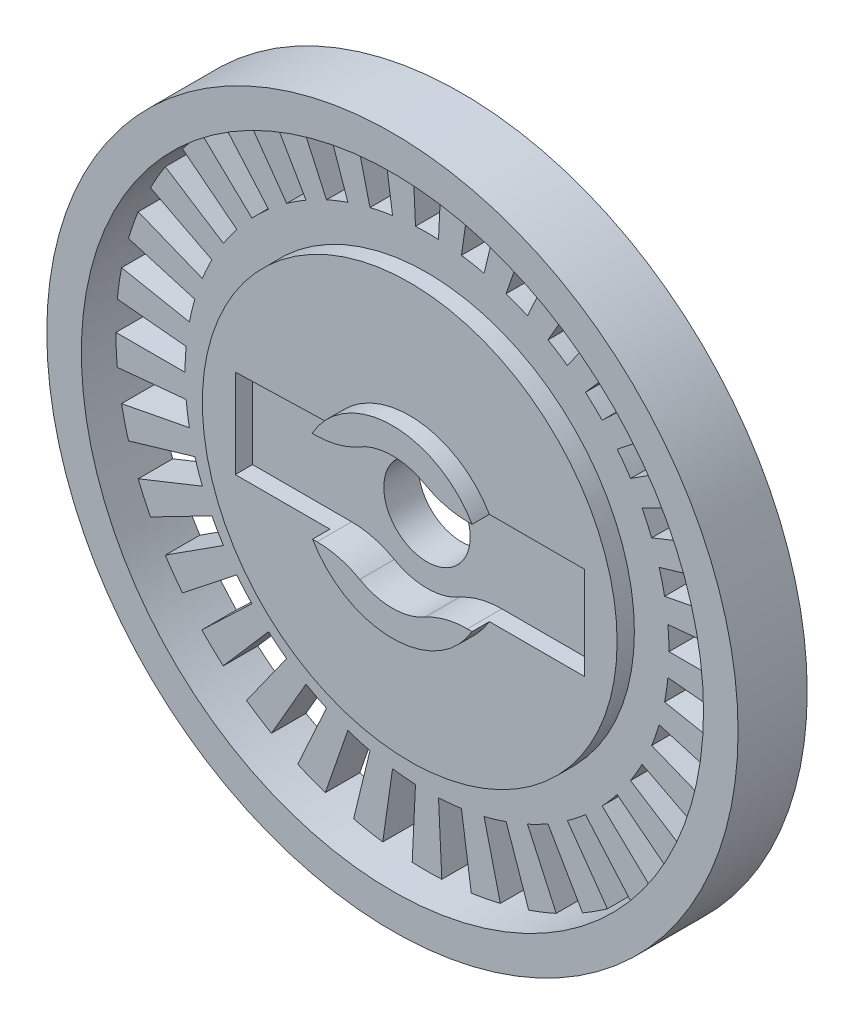
from build123d import *

# Parameters (mm, degrees)
SKETCH1_R           = 20
BOSS_EXTRUDE1_DEPTH = 4
SKETCH2_R           = 2.5
CUT_EXTRUDE1_DEPTH  = 4
CUT_EXTRUDE2_DEPTH  = 2
CUT_EXTRUDE3_DEPTH  = 4
SKETCH5_R           = 18
SKETCH5_R_2         = 12
CUT_EXTRUDE4_DEPTH  = 2
SKETCH6_R           = 13.335707923
SKETCH6_R_2         = 5.335707923
CUT_EXTRUDE5_DEPTH  = 1
FILLET2_R           = 5


with BuildPart() as part:
    # Sketch1 → Boss-Extrude1 (new body)
    with BuildSketch(Plane.XY):
        Circle(SKETCH1_R)
    extrude(amount=BOSS_EXTRUDE1_DEPTH)

    # Sketch2 → Cut-Extrude1 (cut)
    with BuildSketch(Plane.XY.offset(4)):
        Circle(SKETCH2_R)
    extrude(amount=-CUT_EXTRUDE1_DEPTH, mode=Mode.SUBTRACT)

    # Sketch3 → Cut-Extrude2 (cut)
    with BuildSketch(Plane.XY.offset(4)):
        with BuildLine():
            Line((-2.737799224, -2.671157129), (-10.093588243, -2.671157129))
            Line((-10.093588243, -2.671157129), (-10.093588243, 2.468790745))
            Line((-10.093588243, 2.468790745), (-2.739511235, 2.66940128))
            ThreePointArc((-2.739511235, 2.66940128), (-0.013401979, 3.824976521), (2.720738068, 2.688532939))
            Line((2.720738068, 2.688532939), (10.108951703, 2.688532939))
            Line((10.108951703, 2.688532939), (10.108951703, 0.003240604))
            Line((10.108951703, 0.003240604), (10.108951703, -2.686788025))
            Line((10.108951703, -2.686788025), (2.722461223, -2.686788025))
            ThreePointArc((2.722461223, -2.686788025), (-0.010949648, -3.824984327), (-2.737799224, -2.671157129))
        make_face()
    extrude(amount=-CUT_EXTRUDE2_DEPTH, mode=Mode.SUBTRACT)

    # Sketch4 → Cut-Extrude3 (cut)
    with BuildSketch(Plane.XY.offset(4)):
        with BuildLine():
            Line((13.936606916, 1.330784606), (17.918494606, 1.711008779))
            ThreePointArc((17.918494606, 1.711008779), (17.979612105, 0.856474485), (18, 0))
            Line((18, 0), (14, 0))
            ThreePointArc((14, 0), (13.984142749, 0.666146822), (13.936606916, 1.330784606))
        make_face()
        with BuildLine():
            Line((13.936606916, -1.330784606), (17.918494606, -1.711008779))
            ThreePointArc((17.918494606, -1.711008779), (17.816785954, -2.561667089), (17.674716551, -3.406522398))
            Line((17.674716551, -3.406522398), (13.747001762, -2.649517421))
            ThreePointArc((13.747001762, -2.649517421), (13.857500186, -1.992407736), (13.936606916, -1.330784606))
        make_face()
        with BuildLine():
            Line((13.432901631, -3.944255796), (17.270873525, -5.071186023))
            ThreePointArc((17.270873525, -5.071186023), (17.010014737, -5.88722334), (16.710622794, -6.689924202))
            Line((16.710622794, -6.689924202), (12.997151062, -5.203274379))
            ThreePointArc((12.997151062, -5.203274379), (13.230011462, -4.578951486), (13.432901631, -3.944255796))
        make_face()
        with BuildLine():
            Line((12.443696281, -6.415171304), (15.999038076, -8.248077391))
            ThreePointArc((15.999038076, -8.248077391), (15.588457268, -9), (15.142563591, -9.731534714))
            Line((15.142563591, -9.731534714), (11.77754946, -7.568971444))
            ThreePointArc((11.77754946, -7.568971444), (12.124355653, -7), (12.443696281, -6.415171304))
        make_face()
        with BuildLine():
            Line((11.004743326, -8.654225807), (14.148955705, -11.126861752))
            ThreePointArc((14.148955705, -11.126861752), (13.603492338, -11.787493211), (13.027212686, -12.421422207))
            Line((13.027212686, -12.421422207), (10.132276533, -9.661106161))
            ThreePointArc((10.132276533, -9.661106161), (10.580494041, -9.168050275), (11.004743326, -8.654225807))
        make_face()
        with BuildLine():
            Line((9.168050275, -10.580494041), (11.787493211, -13.603492338))
            ThreePointArc((11.787493211, -13.603492338), (11.126861752, -14.148955705), (10.441024372, -14.662367137))
            Line((10.441024372, -14.662367137), (8.120796734, -11.404063329))
            ThreePointArc((8.120796734, -11.404063329), (8.654225807, -11.004743326), (9.168050275, -10.580494041))
        make_face()
        with BuildLine():
            Line((7, -12.124355653), (9, -15.588457268))
            ThreePointArc((9, -15.588457268), (8.248077391, -15.999038076), (7.477470234, -16.373375916))
            Line((7.477470234, -16.373375916), (5.815810182, -12.734847935))
            ThreePointArc((5.815810182, -12.734847935), (6.415171304, -12.443696281), (7, -12.124355653))
        make_face()
        with BuildLine():
            Line((4.578951486, -13.230011462), (5.88722334, -17.010014737))
            ThreePointArc((5.88722334, -17.010014737), (5.071186023, -17.270873525), (4.243660839, -17.49260823))
            Line((4.243660839, -17.49260823), (3.300625097, -13.605361957))
            ThreePointArc((3.300625097, -13.605361957), (3.944255796, -13.432901631), (4.578951486, -13.230011462))
        make_face()
        with BuildLine():
            Line((1.992407736, -13.857500186), (2.561667089, -17.816785954))
            ThreePointArc((2.561667089, -17.816785954), (1.711008779, -17.918494606), (0.856474485, -17.979612105))
            Line((0.856474485, -17.979612105), (0.666146822, -13.984142749))
            ThreePointArc((0.666146822, -13.984142749), (1.330784606, -13.936606916), (1.992407736, -13.857500186))
        make_face()
        with BuildLine():
            Line((-0.666146822, -13.984142749), (-0.856474485, -17.979612105))
            ThreePointArc((-0.856474485, -17.979612105), (-1.711008779, -17.918494606), (-2.561667089, -17.816785954))
            Line((-2.561667089, -17.816785954), (-1.992407736, -13.857500186))
            ThreePointArc((-1.992407736, -13.857500186), (-1.330784606, -13.936606916), (-0.666146822, -13.984142749))
        make_face()
        with BuildLine():
            Line((-3.300625097, -13.605361957), (-4.243660839, -17.49260823))
            ThreePointArc((-4.243660839, -17.49260823), (-5.071186023, -17.270873525), (-5.88722334, -17.010014737))
            Line((-5.88722334, -17.010014737), (-4.578951486, -13.230011462))
            ThreePointArc((-4.578951486, -13.230011462), (-3.944255796, -13.432901631), (-3.300625097, -13.605361957))
        make_face()
        with BuildLine():
            Line((-5.815810182, -12.734847935), (-7.477470234, -16.373375916))
            ThreePointArc((-7.477470234, -16.373375916), (-8.248077391, -15.999038076), (-9, -15.588457268))
            Line((-9, -15.588457268), (-7, -12.124355653))
            ThreePointArc((-7, -12.124355653), (-6.415171304, -12.443696281), (-5.815810182, -12.734847935))
        make_face()
        with BuildLine():
            Line((-8.120796734, -11.404063329), (-10.441024372, -14.662367137))
            ThreePointArc((-10.441024372, -14.662367137), (-11.126861752, -14.148955705), (-11.787493211, -13.603492338))
            Line((-11.787493211, -13.603492338), (-9.168050275, -10.580494041))
            ThreePointArc((-9.168050275, -10.580494041), (-8.654225807, -11.004743326), (-8.120796734, -11.404063329))
        make_face()
        with BuildLine():
            Line((-10.132276533, -9.661106161), (-13.027212686, -12.421422207))
            ThreePointArc((-13.027212686, -12.421422207), (-13.603492338, -11.787493211), (-14.148955705, -11.126861752))
            Line((-14.148955705, -11.126861752), (-11.004743326, -8.654225807))
            ThreePointArc((-11.004743326, -8.654225807), (-10.580494041, -9.168050275), (-10.132276533, -9.661106161))
        make_face()
        with BuildLine():
            Line((-11.77754946, -7.568971444), (-15.142563591, -9.731534714))
            ThreePointArc((-15.142563591, -9.731534714), (-15.588457268, -9), (-15.999038076, -8.248077391))
            Line((-15.999038076, -8.248077391), (-12.443696281, -6.415171304))
            ThreePointArc((-12.443696281, -6.415171304), (-12.124355653, -7), (-11.77754946, -7.568971444))
        make_face()
        with BuildLine():
            Line((-12.997151062, -5.203274379), (-16.710622794, -6.689924202))
            ThreePointArc((-16.710622794, -6.689924202), (-17.010014737, -5.88722334), (-17.270873525, -5.071186023))
            Line((-17.270873525, -5.071186023), (-13.432901631, -3.944255796))
            ThreePointArc((-13.432901631, -3.944255796), (-13.230011462, -4.578951486), (-12.997151062, -5.203274379))
        make_face()
        with BuildLine():
            Line((-13.747001762, -2.649517421), (-17.674716551, -3.406522398))
            ThreePointArc((-17.674716551, -3.406522398), (-17.816785954, -2.561667089), (-17.918494606, -1.711008779))
            Line((-17.918494606, -1.711008779), (-13.936606916, -1.330784606))
            ThreePointArc((-13.936606916, -1.330784606), (-13.857500186, -1.992407736), (-13.747001762, -2.649517421))
        make_face()
        with BuildLine():
            Line((-14, 0), (-18, 0))
            ThreePointArc((-18, 0), (-17.979612105, 0.856474485), (-17.918494606, 1.711008779))
            Line((-17.918494606, 1.711008779), (-13.936606916, 1.330784606))
            ThreePointArc((-13.936606916, 1.330784606), (-13.984142749, 0.666146822), (-14, 0))
        make_face()
        with BuildLine():
            Line((-13.747001762, 2.649517421), (-17.674716551, 3.406522398))
            ThreePointArc((-17.674716551, 3.406522398), (-17.49260823, 4.243660839), (-17.270873525, 5.071186023))
            Line((-17.270873525, 5.071186023), (-13.432901631, 3.944255796))
            ThreePointArc((-13.432901631, 3.944255796), (-13.605361957, 3.300625097), (-13.747001762, 2.649517421))
        make_face()
        with BuildLine():
            Line((-12.997151062, 5.203274379), (-16.710622794, 6.689924202))
            ThreePointArc((-16.710622794, 6.689924202), (-16.373375916, 7.477470234), (-15.999038076, 8.248077391))
            Line((-15.999038076, 8.248077391), (-12.443696281, 6.415171304))
            ThreePointArc((-12.443696281, 6.415171304), (-12.734847935, 5.815810182), (-12.997151062, 5.203274379))
        make_face()
        with BuildLine():
            Line((-11.77754946, 7.568971444), (-15.142563591, 9.731534714))
            ThreePointArc((-15.142563591, 9.731534714), (-14.662367137, 10.441024372), (-14.148955705, 11.126861752))
            Line((-14.148955705, 11.126861752), (-11.004743326, 8.654225807))
            ThreePointArc((-11.004743326, 8.654225807), (-11.404063329, 8.120796734), (-11.77754946, 7.568971444))
        make_face()
        with BuildLine():
            Line((-10.132276533, 9.661106161), (-13.027212686, 12.421422207))
            ThreePointArc((-13.027212686, 12.421422207), (-12.421422207, 13.027212686), (-11.787493211, 13.603492338))
            Line((-11.787493211, 13.603492338), (-9.168050275, 10.580494041))
            ThreePointArc((-9.168050275, 10.580494041), (-9.661106161, 10.132276533), (-10.132276533, 9.661106161))
        make_face()
        with BuildLine():
            Line((-8.120796734, 11.404063329), (-10.441024372, 14.662367137))
            ThreePointArc((-10.441024372, 14.662367137), (-9.731534714, 15.142563591), (-9, 15.588457268))
            Line((-9, 15.588457268), (-7, 12.124355653))
            ThreePointArc((-7, 12.124355653), (-7.568971444, 11.77754946), (-8.120796734, 11.404063329))
        make_face()
        with BuildLine():
            Line((-5.815810182, 12.734847935), (-7.477470234, 16.373375916))
            ThreePointArc((-7.477470234, 16.373375916), (-6.689924202, 16.710622794), (-5.88722334, 17.010014737))
            Line((-5.88722334, 17.010014737), (-4.578951486, 13.230011462))
            ThreePointArc((-4.578951486, 13.230011462), (-5.203274379, 12.997151062), (-5.815810182, 12.734847935))
        make_face()
        with BuildLine():
            Line((-3.300625097, 13.605361957), (-4.243660839, 17.49260823))
            ThreePointArc((-4.243660839, 17.49260823), (-3.406522398, 17.674716551), (-2.561667089, 17.816785954))
            Line((-2.561667089, 17.816785954), (-1.992407736, 13.857500186))
            ThreePointArc((-1.992407736, 13.857500186), (-2.649517421, 13.747001762), (-3.300625097, 13.605361957))
        make_face()
        with BuildLine():
            Line((-0.666146822, 13.984142749), (-0.856474485, 17.979612105))
            ThreePointArc((-0.856474485, 17.979612105), (0, 18), (0.856474485, 17.979612105))
            Line((0.856474485, 17.979612105), (0.666146822, 13.984142749))
            ThreePointArc((0.666146822, 13.984142749), (0, 14), (-0.666146822, 13.984142749))
        make_face()
        with BuildLine():
            Line((1.992407736, 13.857500186), (2.561667089, 17.816785954))
            ThreePointArc((2.561667089, 17.816785954), (3.406522398, 17.674716551), (4.243660839, 17.49260823))
            Line((4.243660839, 17.49260823), (3.300625097, 13.605361957))
            ThreePointArc((3.300625097, 13.605361957), (2.649517421, 13.747001762), (1.992407736, 13.857500186))
        make_face()
        with BuildLine():
            Line((4.578951486, 13.230011462), (5.88722334, 17.010014737))
            ThreePointArc((5.88722334, 17.010014737), (6.689924202, 16.710622794), (7.477470234, 16.373375916))
            Line((7.477470234, 16.373375916), (5.815810182, 12.734847935))
            ThreePointArc((5.815810182, 12.734847935), (5.203274379, 12.997151062), (4.578951486, 13.230011462))
        make_face()
        with BuildLine():
            Line((7, 12.124355653), (9, 15.588457268))
            ThreePointArc((9, 15.588457268), (9.731534714, 15.142563591), (10.441024372, 14.662367137))
            Line((10.441024372, 14.662367137), (8.120796734, 11.404063329))
            ThreePointArc((8.120796734, 11.404063329), (7.568971444, 11.77754946), (7, 12.124355653))
        make_face()
        with BuildLine():
            Line((9.168050275, 10.580494041), (11.787493211, 13.603492338))
            ThreePointArc((11.787493211, 13.603492338), (12.421422207, 13.027212686), (13.027212686, 12.421422207))
            Line((13.027212686, 12.421422207), (10.132276533, 9.661106161))
            ThreePointArc((10.132276533, 9.661106161), (9.661106161, 10.132276533), (9.168050275, 10.580494041))
        make_face()
        with BuildLine():
            Line((11.004743326, 8.654225807), (14.148955705, 11.126861752))
            ThreePointArc((14.148955705, 11.126861752), (14.662367137, 10.441024372), (15.142563591, 9.731534714))
            Line((15.142563591, 9.731534714), (11.77754946, 7.568971444))
            ThreePointArc((11.77754946, 7.568971444), (11.404063329, 8.120796734), (11.004743326, 8.654225807))
        make_face()
        with BuildLine():
            Line((12.443696281, 6.415171304), (15.999038076, 8.248077391))
            ThreePointArc((15.999038076, 8.248077391), (16.373375916, 7.477470234), (16.710622794, 6.689924202))
            Line((16.710622794, 6.689924202), (12.997151062, 5.203274379))
            ThreePointArc((12.997151062, 5.203274379), (12.734847935, 5.815810182), (12.443696281, 6.415171304))
        make_face()
        with BuildLine():
            Line((13.432901631, 3.944255796), (17.270873525, 5.071186023))
            ThreePointArc((17.270873525, 5.071186023), (17.49260823, 4.243660839), (17.674716551, 3.406522398))
            Line((17.674716551, 3.406522398), (13.747001762, 2.649517421))
            ThreePointArc((13.747001762, 2.649517421), (13.605361957, 3.300625097), (13.432901631, 3.944255796))
        make_face()
    extrude(amount=-CUT_EXTRUDE3_DEPTH, mode=Mode.SUBTRACT)

    # Sketch5 → Cut-Extrude4 (cut)
    with BuildSketch(Plane.XY.offset(4)):
        Circle(SKETCH5_R)
        Circle(SKETCH5_R_2, mode=Mode.SUBTRACT)
    extrude(amount=-CUT_EXTRUDE4_DEPTH, mode=Mode.SUBTRACT)

    # Sketch6 → Cut-Extrude5 (cut)
    with BuildSketch(Plane.XY.offset(4)):
        Circle(SKETCH6_R)
        Circle(SKETCH6_R_2, mode=Mode.SUBTRACT)
    extrude(amount=-CUT_EXTRUDE5_DEPTH, mode=Mode.SUBTRACT)

    # Fillet2
    fillet2_edges = [part.edges().sort_by_distance(p)[0] for p in [
        (2.722461223, -2.686788025, 3),
        (-2.737799224, -2.671157129, 3),
        (-2.739511235, 2.66940128, 3),
        (2.720738068, 2.688532939, 3),
    ]]
    fillet(fillet2_edges, radius=FILLET2_R)


solid = part.part
